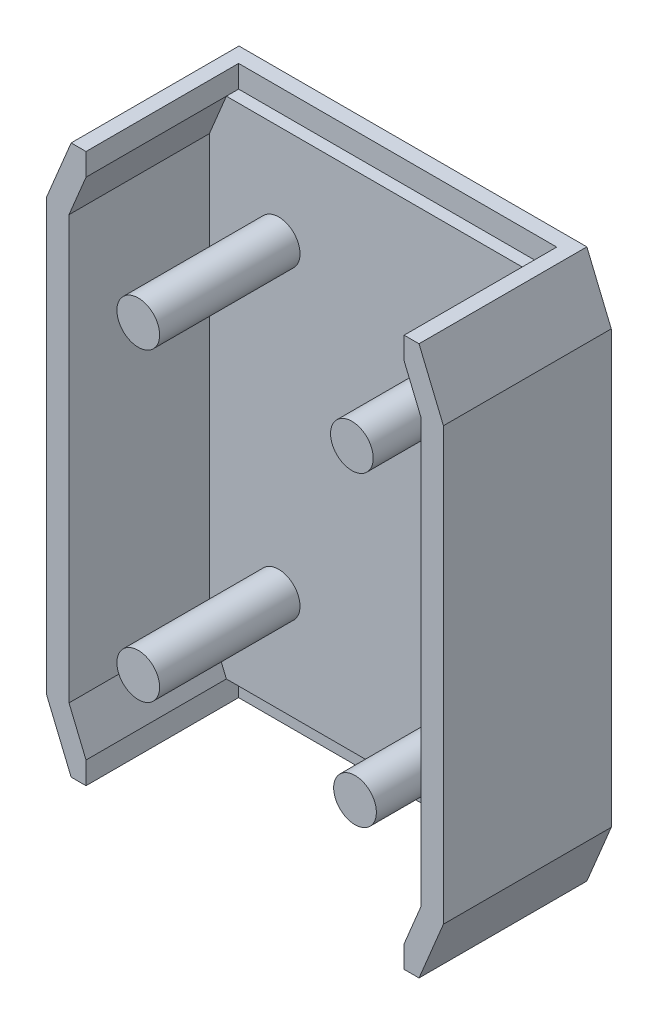
from build123d import *

# Parameters (mm, degrees)
BOSS_EXTRUDE1_DEPTH = 5.715
BOSS_EXTRUDE2_DEPTH = 29.21
SKETCH3_W           = 66.200858932
SKETCH3_H           = 4.6355
CUT_EXTRUDE1_DEPTH  = 31.75
SKETCH4_R           = 4.445
BOSS_EXTRUDE3_DEPTH = 29.21


with BuildPart() as part:
    # Sketch1 → Boss-Extrude1 (new body)
    with BuildSketch(Plane.XY):
        Polygon((41.275, 44.914422768), (36.195, 57.15), (-36.195, 57.15), (-41.275, 44.914422768), (-41.275, -44.914422768), (-36.195, -57.15), (36.195, -57.15), (41.275, -44.914422768), align=None)
    extrude(amount=BOSS_EXTRUDE1_DEPTH)

    # Sketch2 → Boss-Extrude2 (add)
    with BuildSketch(Plane.XY.offset(5.715)):
        Polygon((-41.275, 44.914422768), (-41.275, -44.914422768), (-36.195, -57.15), (36.195, -57.15), (41.275, -44.914422768), (41.275, 44.914422768), (36.195, 57.15), (-36.195, 57.15), align=None)
        Polygon((-33.100429466, 52.5145), (-36.6395, 43.99037188), (-36.6395, -43.99037188), (-33.100429466, -52.5145), (33.100429466, -52.5145), (36.6395, -43.99037188), (36.6395, 43.99037188), (33.100429466, 52.5145), align=None, mode=Mode.SUBTRACT)
    extrude(amount=BOSS_EXTRUDE2_DEPTH)

    # Sketch3 → Cut-Extrude1 (cut)
    with BuildSketch(Plane.XY.offset(34.925)):
        with Locations((0, 54.83225)):
            Rectangle(SKETCH3_W, SKETCH3_H)
    cut_extrude1 = extrude(amount=-CUT_EXTRUDE1_DEPTH, mode=Mode.SUBTRACT)

    # Mirror1: Cut-Extrude1 across plane
    add(cut_extrude1.mirror(Plane.ZX), mode=Mode.SUBTRACT)

    # Sketch4 → Boss-Extrude3 (add)
    with BuildSketch(Plane.XY.offset(5.715)):
        with Locations((22.874903427, -31.75)):
            Circle(SKETCH4_R)
        with Locations((-22.225, -31.75)):
            Circle(SKETCH4_R)
        with Locations((22.225, 31.75)):
            Circle(SKETCH4_R)
        with Locations((-22.225, 31.75)):
            Circle(SKETCH4_R)
    extrude(amount=BOSS_EXTRUDE3_DEPTH)


solid = part.part
